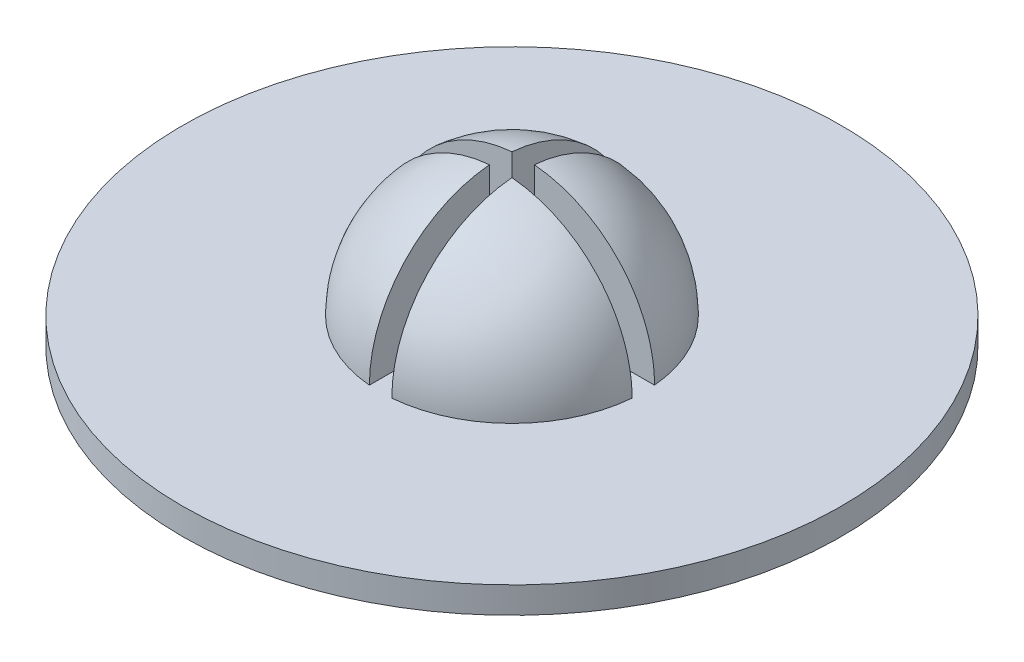
from build123d import *

# Parameters (mm, degrees)
SKETCH1_R           = 25
BOSS_EXTRUDE1_DEPTH = 2
REVOLVE3_ANGLE      = 180
SKETCH7_W           = 1.7
SKETCH7_H           = 1.7
SKETCH7_W_2         = 9.15
SKETCH7_H_2         = 9.15
CUT_EXTRUDE1_DEPTH  = 10


with BuildPart() as part:
    # Sketch1 → Boss-Extrude1 (new body)
    with BuildSketch(Plane(origin=(0, 0, 0), x_dir=(1, 0, 0), z_dir=(0, 1, 0))):
        Circle(SKETCH1_R)
    extrude(amount=-BOSS_EXTRUDE1_DEPTH)

    # Sketch6 → Revolve3 (revolve)
    with BuildSketch(Plane(origin=(0, 0, 0), x_dir=(1, 0, 0), z_dir=(0, 1, 0))):
        with BuildLine():
            Line((-10, 0), (10, 0))
            ThreePointArc((10, 0), (0, 10), (-10, 0))
        make_face()
    revolve(axis=Axis((-10, 0, 0), (1, 0, 0)), revolution_arc=REVOLVE3_ANGLE)

    # Sketch7 → Cut-Extrude1 (cut)
    with BuildSketch(Plane(origin=(0, 0, 0), x_dir=(1, 0, 0), z_dir=(0, 1, 0))):
        Rectangle(SKETCH7_W, SKETCH7_H)
        with Locations((-5.425, 0)):
            Rectangle(SKETCH7_W_2, SKETCH7_H)
        with Locations((0, 5.425)):
            Rectangle(SKETCH7_W, SKETCH7_H_2)
        with Locations((5.425, 0)):
            Rectangle(SKETCH7_W_2, SKETCH7_H)
        with Locations((0, -5.425)):
            Rectangle(SKETCH7_W, SKETCH7_H_2)
    extrude(amount=CUT_EXTRUDE1_DEPTH, mode=Mode.SUBTRACT)


solid = part.part
